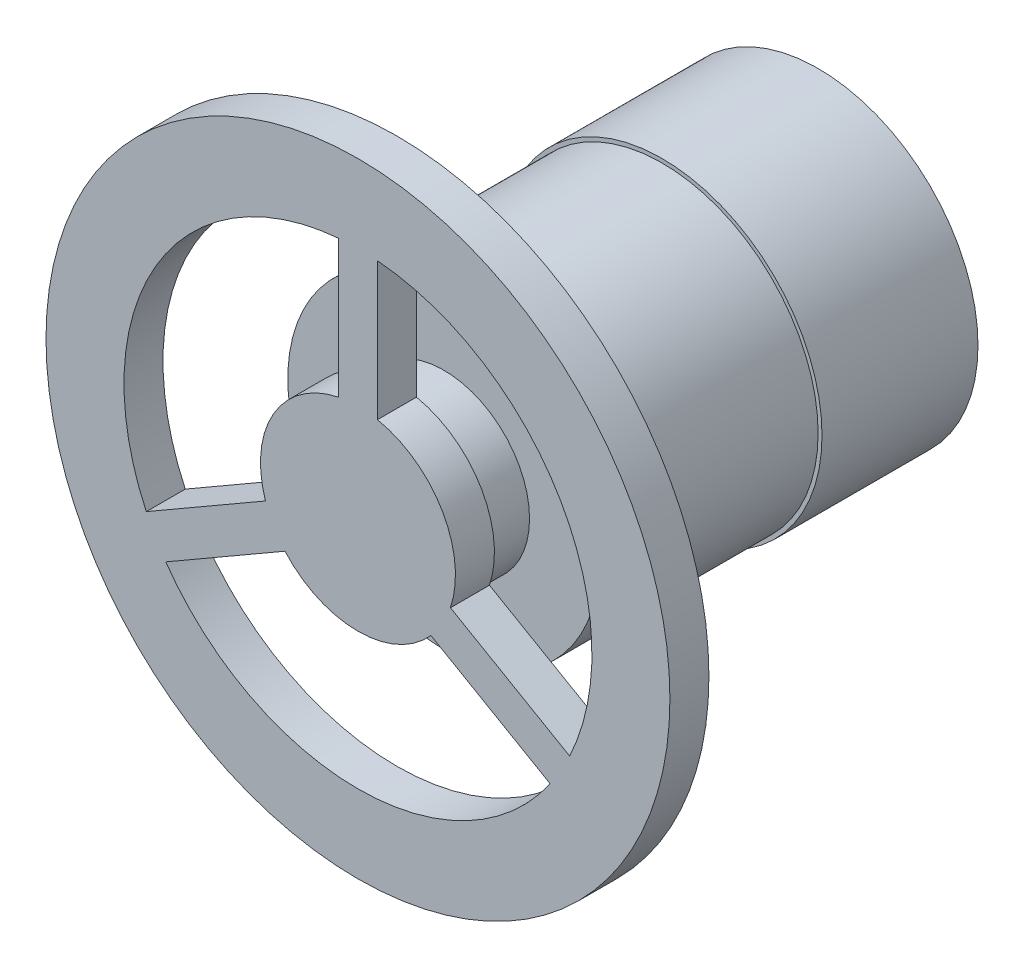
from build123d import *

# Parameters (mm, degrees)
SKETCH_1_R      = 20.5
EXTRUDE_1_DEPTH = 20
SKETCH_4_R      = 20
EXTRUDE_4_DEPTH = 28
SKETCH_2_R      = 11
EXTRUDE_2_DEPTH = 6
SKETCH_3_R      = 40
EXTRUDE_3_DEPTH = 5


with BuildPart() as part:
    # 草图1 → 凸台-拉伸1 (new body)
    with BuildSketch(Plane.XY):
        Circle(SKETCH_1_R)
    extrude(amount=EXTRUDE_1_DEPTH)

    # 草图4 → 凸台-拉伸4 (add)
    with BuildSketch(Plane.XY.offset(20)):
        Circle(SKETCH_4_R)
    extrude(amount=EXTRUDE_4_DEPTH)

    # 草图2 → 凸台-拉伸2 (add)
    with BuildSketch(Plane.XY.offset(48)):
        Circle(SKETCH_2_R)
    extrude(amount=EXTRUDE_2_DEPTH)

    # 草图3 → 凸台-拉伸3 (add)
    with BuildSketch(Plane.XY.offset(54)):
        Circle(SKETCH_3_R)
        with BuildLine():
            Line((-2.5, 12.247448714), (-2.5, 29.895651858))
            ThreePointArc((-2.5, 29.895651858), (-25.980762114, 15), (-27.140393972, -12.782762419))
            Line((-27.140393972, -12.782762419), (-11.856601718, -3.958660847))
            ThreePointArc((-11.856601718, -3.958660847), (-10.825317547, 6.25), (-2.5, 12.247448714))
        make_face(mode=Mode.SUBTRACT)
        with BuildLine():
            Line((11.856601718, -3.958660847), (27.140393972, -12.782762419))
            ThreePointArc((27.140393972, -12.782762419), (25.980762114, 15), (2.5, 29.895651858))
            Line((2.5, 29.895651858), (2.5, 12.247448714))
            ThreePointArc((2.5, 12.247448714), (10.825317547, 6.25), (11.856601718, -3.958660847))
        make_face(mode=Mode.SUBTRACT)
        with BuildLine():
            Line((9.356601718, -8.288787866), (24.640393972, -17.112889438))
            ThreePointArc((24.640393972, -17.112889438), (0, -30), (-24.640393972, -17.112889438))
            Line((-24.640393972, -17.112889438), (-9.356601718, -8.288787866))
            ThreePointArc((-9.356601718, -8.288787866), (0, -12.5), (9.356601718, -8.288787866))
        make_face(mode=Mode.SUBTRACT)
    extrude(amount=EXTRUDE_3_DEPTH)


solid = part.part
